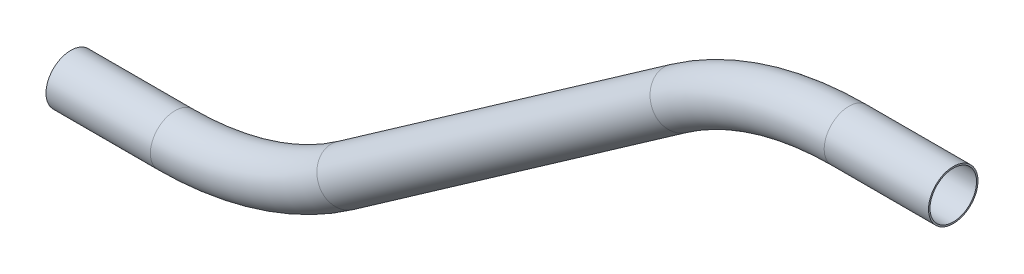
from build123d import *

# Parameters (mm, degrees)
SKETCH5_R   = 6.35
SKETCH5_R_2 = 5.969


with BuildPart() as part:
    # Sweep1: sweep along a path in Sketch4
    with BuildLine(Plane.XY) as sweep1_path:
        Line((121.865926636, 47.432526586), (95.091694349, 47.432526586))
        ThreePointArc((95.091694349, 47.432526586), (72.177912426, 43.905758233), (51.385169899, 33.651912361))
        Line((51.385169899, 33.651912361), (-34.092088176, -26.199908089))
        ThreePointArc((-34.092088176, -26.199908089), (-54.884830704, -36.453753961), (-77.798612626, -39.980522314))
        Line((-77.798612626, -39.980522314), (-104.572844914, -39.980522314))
    # Sketch5 → Sweep1 (sweep)
    with BuildSketch(Plane(origin=(121.865926636, 47.432526586, 0), x_dir=(0, 0, 1), z_dir=(-1, 0, 0))):
        Circle(SKETCH5_R)
        Circle(SKETCH5_R_2, mode=Mode.SUBTRACT)
    sweep(path=sweep1_path.line)


solid = part.part
